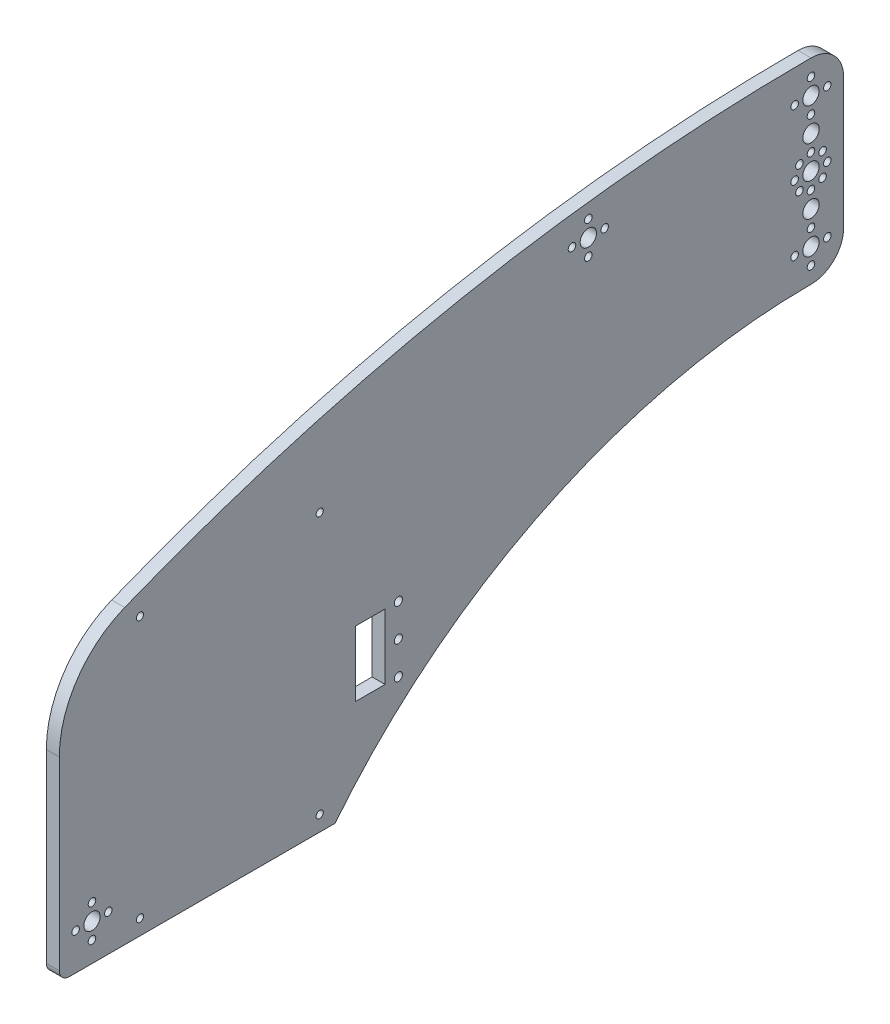
from build123d import *

# Parameters (mm, degrees)
SKETCH1_R           = 4
SKETCH1_R_2         = 1.85
SKETCH1_R_3         = 2
SKETCH1_R_4         = 1.75
SKETCH1_W           = 14.5
SKETCH1_H           = 32
BOSS_EXTRUDE2_DEPTH = 6.35


with BuildPart() as part:
    # Sketch1 → Boss-Extrude2 (new body)
    with BuildSketch(Plane(origin=(0, 0, 0), x_dir=(0, 0, -1), z_dir=(1, 0, 0))):
        with BuildLine():
            Line((-16, 77.649446494), (-16, -13))
            ThreePointArc((-16, -13), (-14.535533906, -16.535533906), (-11, -18))
            Line((-11, -18), (119, -18))
            ThreePointArc((119, -18), (222.7396039, 64.546181173), (352, 94))
            ThreePointArc((352, 94), (363.313708499, 98.686291501), (368, 110))
            Line((368, 110), (368, 174))
            ThreePointArc((368, 174), (363.313708499, 185.313708499), (352, 190))
            ThreePointArc((352, 190), (180.885272405, 173.600745723), (16, 125))
            ThreePointArc((16, 125), (-7.249835994, 106.224238345), (-16, 77.649446494))
        make_face()
        with Locations((352, 110)):
            Circle(SKETCH1_R, mode=Mode.SUBTRACT)
        with Locations((352, 118)):
            Circle(SKETCH1_R_2, mode=Mode.SUBTRACT)
        with Locations((352, 126)):
            Circle(SKETCH1_R, mode=Mode.SUBTRACT)
        with Locations((352, 134)):
            Circle(SKETCH1_R_2, mode=Mode.SUBTRACT)
        with Locations((352, 142)):
            Circle(SKETCH1_R, mode=Mode.SUBTRACT)
        with Locations((360, 110)):
            Circle(SKETCH1_R_2, mode=Mode.SUBTRACT)
        with Locations((352, 102)):
            Circle(SKETCH1_R_2, mode=Mode.SUBTRACT)
        with Locations((344, 110)):
            Circle(SKETCH1_R_2, mode=Mode.SUBTRACT)
        with Locations((346.343145751, 136.343145751)):
            Circle(SKETCH1_R_2, mode=Mode.SUBTRACT)
        with Locations((344, 142)):
            Circle(SKETCH1_R_2, mode=Mode.SUBTRACT)
        with Locations((346.343145751, 147.656854249)):
            Circle(SKETCH1_R_2, mode=Mode.SUBTRACT)
        with Locations((352, 150)):
            Circle(SKETCH1_R_2, mode=Mode.SUBTRACT)
        with Locations((357.656854249, 147.656854249)):
            Circle(SKETCH1_R_2, mode=Mode.SUBTRACT)
        with Locations((360, 142)):
            Circle(SKETCH1_R_2, mode=Mode.SUBTRACT)
        with Locations((357.656854249, 136.343145751)):
            Circle(SKETCH1_R_2, mode=Mode.SUBTRACT)
        with Locations((344, 174)):
            Circle(SKETCH1_R_2, mode=Mode.SUBTRACT)
        with Locations((352, 182)):
            Circle(SKETCH1_R_2, mode=Mode.SUBTRACT)
        with Locations((360, 174)):
            Circle(SKETCH1_R_2, mode=Mode.SUBTRACT)
        with Locations((352, 158)):
            Circle(SKETCH1_R, mode=Mode.SUBTRACT)
        with Locations((352, 166)):
            Circle(SKETCH1_R_2, mode=Mode.SUBTRACT)
        with Locations((352, 174)):
            Circle(SKETCH1_R, mode=Mode.SUBTRACT)
        Circle(SKETCH1_R, mode=Mode.SUBTRACT)
        with Locations((8, 0)):
            Circle(SKETCH1_R_2, mode=Mode.SUBTRACT)
        with Locations((0, -8)):
            Circle(SKETCH1_R_2, mode=Mode.SUBTRACT)
        with Locations((-8, 0)):
            Circle(SKETCH1_R_2, mode=Mode.SUBTRACT)
        with Locations((0, 8)):
            Circle(SKETCH1_R_2, mode=Mode.SUBTRACT)
        with Locations((150, 28.62526107)):
            Circle(SKETCH1_R_3, mode=Mode.SUBTRACT)
        with Locations((150, 44.62526107)):
            Circle(SKETCH1_R_3, mode=Mode.SUBTRACT)
        with Locations((150, 60.62526107)):
            Circle(SKETCH1_R_3, mode=Mode.SUBTRACT)
        with Locations((243, 168.269053261)):
            Circle(SKETCH1_R, mode=Mode.SUBTRACT)
        with Locations((251, 168.269053261)):
            Circle(SKETCH1_R_2, mode=Mode.SUBTRACT)
        with Locations((243, 160.269053261)):
            Circle(SKETCH1_R_2, mode=Mode.SUBTRACT)
        with Locations((235, 168.269053261)):
            Circle(SKETCH1_R_2, mode=Mode.SUBTRACT)
        with Locations((243, 176.269053261)):
            Circle(SKETCH1_R_2, mode=Mode.SUBTRACT)
        with Locations((23.5, 117.5)):
            Circle(SKETCH1_R_4, mode=Mode.SUBTRACT)
        with Locations((111.5, 117.5)):
            Circle(SKETCH1_R_4, mode=Mode.SUBTRACT)
        with Locations((111.5, -10.5)):
            Circle(SKETCH1_R_4, mode=Mode.SUBTRACT)
        with Locations((23.5, -10.5)):
            Circle(SKETCH1_R_4, mode=Mode.SUBTRACT)
        with Locations((136.25, 44.62526107)):
            Rectangle(SKETCH1_W, SKETCH1_H, mode=Mode.SUBTRACT)
    extrude(amount=BOSS_EXTRUDE2_DEPTH)


solid = part.part
